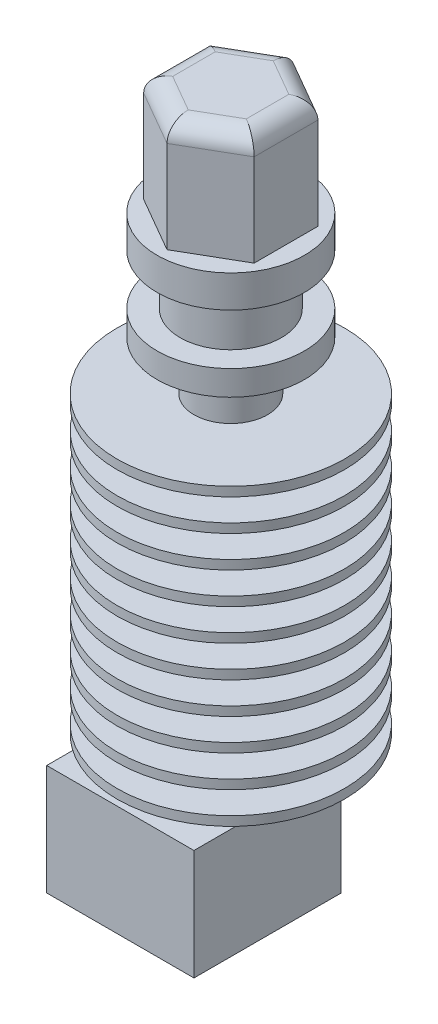
from build123d import *

# Parameters (mm, degrees)
ESBO_O3_W                = 16
ESBO_O3_H                = 16
RESSALTO_EXTRUS_O1_DEPTH = 12
ESBO_O4_R                = 3
RESSALTO_EXTRUS_O2_DEPTH = 5
RESSALTO_EXTRUS_O2_TAPER = 26
RESSALTO_EXTRUS_O3_DEPTH = 12
FILETE1_R                = 2


with BuildPart() as part:
    # Esboço1 → Revolução1 (revolve)
    with BuildSketch(Plane.XY):
        Polygon((0, 51.659238703), (0, 1.659238703), (2, 1.659238703), (2, 2.659238703), (12.35, 2.659238703), (12.35, 3.659238703), (4, 3.659238703), (4, 6.103683147), (12.35, 6.103683147), (12.35, 7.103683147), (4, 7.103683147), (4, 9.548127592), (12.35, 9.548127592), (12.35, 10.548127592), (4, 10.548127592), (4, 12.992572036), (12.35, 12.992572036), (12.35, 13.992572036), (4, 13.992572036), (4, 16.437016481), (12.35, 16.437016481), (12.35, 17.437016481), (4, 17.437016481), (4, 19.881460925), (12.35, 19.881460925), (12.35, 20.881460925), (4, 20.881460925), (4, 23.32590537), (12.35, 23.32590537), (12.35, 24.32590537), (4, 24.32590537), (4, 26.770349814), (12.35, 26.770349814), (12.35, 27.770349814), (4, 27.770349814), (4, 30.214794259), (12.35, 30.214794259), (12.35, 31.214794259), (4, 31.214794259), (4, 33.659238703), (12.35, 33.659238703), (12.35, 34.659238703), (4, 34.659238703), (4, 39.959238703), (8, 39.959238703), (8, 42.659238703), (5.5, 42.659238703), (5.5, 48.159238703), (8, 48.159238703), (8, 51.659238703), align=None)
    revolve(axis=Axis((0, 51.659238703, 0), (0, -1, 0)))

    # Esboço3 → Ressalto-extrusão1 (add)
    with BuildSketch(Plane.XZ.offset(-1.659238703)):
        with Locations((0, 4)):
            Rectangle(ESBO_O3_W, ESBO_O3_H)
    extrude(amount=RESSALTO_EXTRUS_O1_DEPTH)

    # Esboço4 → Ressalto-extrusão2 (add)
    with BuildSketch(Plane.XZ.offset(10.340761297)):
        Circle(ESBO_O4_R)
    extrude(amount=RESSALTO_EXTRUS_O2_DEPTH, taper=RESSALTO_EXTRUS_O2_TAPER)

    # Esboço5 → Ressalto-extrusão3 (add)
    with BuildSketch(Plane(origin=(0, 51.659238703, 0), x_dir=(1, 0, 0), z_dir=(0, 1, 0))):
        Polygon((0, -6.92820323), (6, -3.464101615), (6, 3.464101615), (0, 6.92820323), (-6, 3.464101615), (-6, -3.464101615), align=None)
    extrude(amount=RESSALTO_EXTRUS_O3_DEPTH)

    # Filete1
    filete1_edges = [part.edges().sort_by_distance(p)[0] for p in [
        (-3, 63.659238703, 5.196152423),
        (3, 63.659238703, 5.196152423),
        (6, 63.659238703, 0),
        (3, 63.659238703, -5.196152423),
        (-3, 63.659238703, -5.196152423),
        (-6, 63.659238703, 0),
    ]]
    fillet(filete1_edges, radius=FILETE1_R)


solid = part.part
